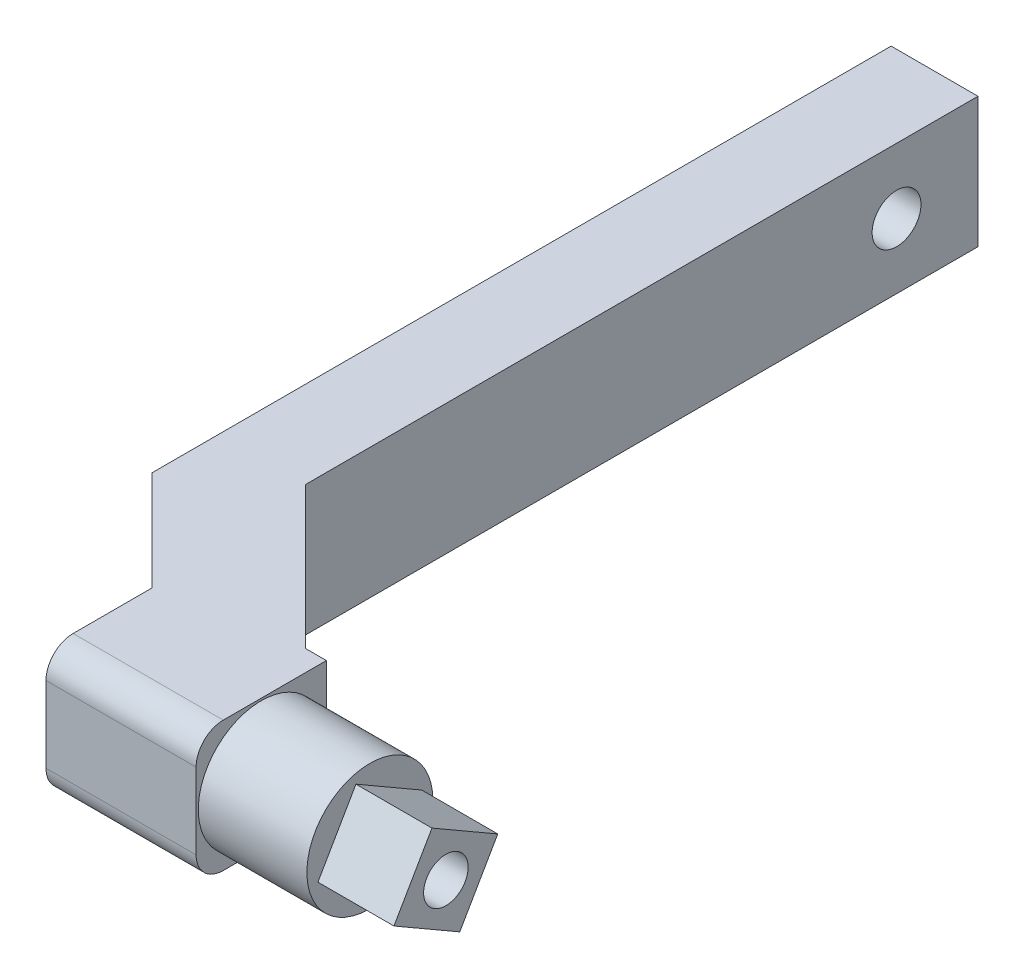
from build123d import *

# Parameters (mm, degrees)
EXTRUDE_1_DEPTH          = 24
SKETCH_2_W               = 24
SKETCH_2_H               = 24
SKETCH_2_R               = 11.6
CUT_EXTRUDE_1_DEPTH      = 20
SKETCH_6_R               = 4.1
CUT_EXTRUDE_3_DEPTH      = 1
CUT_EXTRUDE_3_DEPTH_BACK = 67
FILLET_3_R               = 5
EXTRUDE_2_DEPTH          = 14
SKETCH_10_R              = 4.1
CUT_EXTRUDE_4_DEPTH      = 81
SKETCH_12_R              = 11.1
CUT_EXTRUDE_5_DEPTH      = 7.1
SKETCH_13_R              = 4.5
CUT_EXTRUDE_6_DEPTH      = 73.9


with BuildPart() as part:
    # Эскиз1 → Бобышка-Вытянуть1 (new body)
    with BuildSketch(Plane(origin=(0, 0, 0), x_dir=(1, 0, 0), z_dir=(0, 1, 0))):
        Polygon((-37.857864376, 37.857864376), (-36, 36), (-36, 159.857864376), (-52, 159.857864376), (-52, 23.715728753), align=None)
        Polygon((-36, 23.715728753), (-36, 36), (-37.857864376, 37.857864376), (-52, 23.715728753), align=None)
        Polygon((-33.642135624, 5.357864376), (-14.142135624, -14.142135624), (-14.142135624, 9.857864376), (-9.857864376, 9.857864376), (-36, 36), (-36, 23.715728753), (-52, 23.715728753), align=None)
        Polygon((-14.142135624, -14.142135624), (0, 0), (-9.857864376, 9.857864376), (-14.142135624, 9.857864376), align=None)
        Polygon((-9.857864376, 9.857864376), (0, 0), (-14.142135624, -14.142135624), (14, -14.142135624), (14, 9.857864376), align=None)
        Polygon((-33.642135624, -14.142135624), (-14.142135624, -14.142135624), (-33.642135624, 5.357864376), align=None)
    extrude(amount=EXTRUDE_1_DEPTH)

    # Эскиз2 → Вырез-Вытянуть1 (cut)
    with BuildSketch(Plane(origin=(14, 0, 0), x_dir=(0, 0, -1), z_dir=(1, 0, 0))):
        with Locations((-2.142135624, 12)):
            Rectangle(SKETCH_2_W, SKETCH_2_H)
        with Locations((-2.142135624, 12)):
            Circle(SKETCH_2_R, mode=Mode.SUBTRACT)
    extrude(amount=-CUT_EXTRUDE_1_DEPTH, mode=Mode.SUBTRACT)

    # Эскиз6 → Вырез-Вытянуть3 (cut, two sides)
    with BuildSketch(Plane(origin=(14, 0, 0), x_dir=(0, 0, -1), z_dir=(1, 0, 0))) as cut_extrude_3_sk:
        with Locations((-2.142135624, 12)):
            Circle(SKETCH_6_R)
    extrude(amount=CUT_EXTRUDE_3_DEPTH, mode=Mode.SUBTRACT)
    extrude(cut_extrude_3_sk.sketch, amount=-CUT_EXTRUDE_3_DEPTH_BACK, mode=Mode.SUBTRACT)

    # Скругление3
    fillet_3_edges = [part.edges().sort_by_distance(p)[0] for p in [
        (-19.821067812, 0, 14.142135624),
        (-19.821067812, 24, 14.142135624),
    ]]
    fillet(fillet_3_edges, radius=FILLET_3_R)

    # Эскиз9 → Бобышка-Вытянуть2 (add)
    with BuildSketch(Plane(origin=(14, 0, 0), x_dir=(0, 0, -1), z_dir=(1, 0, 0))):
        Polygon((-4.70431345, 21.562177826), (-11.70431345, 9.437822174), (0.420042203, 2.437822174), (7.420042203, 14.562177826), align=None)
    extrude(amount=EXTRUDE_2_DEPTH)

    # Эскиз10 → Вырез-Вытянуть4 (cut, through all)
    with BuildSketch(Plane(origin=(28, 0, 0), x_dir=(0, 0, -1), z_dir=(1, 0, 0))):
        with Locations((-2.142135624, 12)):
            Circle(SKETCH_10_R)
    extrude(amount=-CUT_EXTRUDE_4_DEPTH, mode=Mode.SUBTRACT)

    # Эскиз12 → Вырез-Вытянуть5 (cut)
    with BuildSketch(Plane.ZY.offset(52)):
        with Locations((-144.857864376, 12)):
            Circle(SKETCH_12_R)
    extrude(amount=-CUT_EXTRUDE_5_DEPTH, mode=Mode.SUBTRACT)

    # Эскиз13 → Вырез-Вытянуть6 (cut, through all)
    with BuildSketch(Plane.ZY.offset(44.9)):
        with Locations((-144.857864376, 12)):
            Circle(SKETCH_13_R)
    extrude(amount=-CUT_EXTRUDE_6_DEPTH, mode=Mode.SUBTRACT)


solid = part.part
